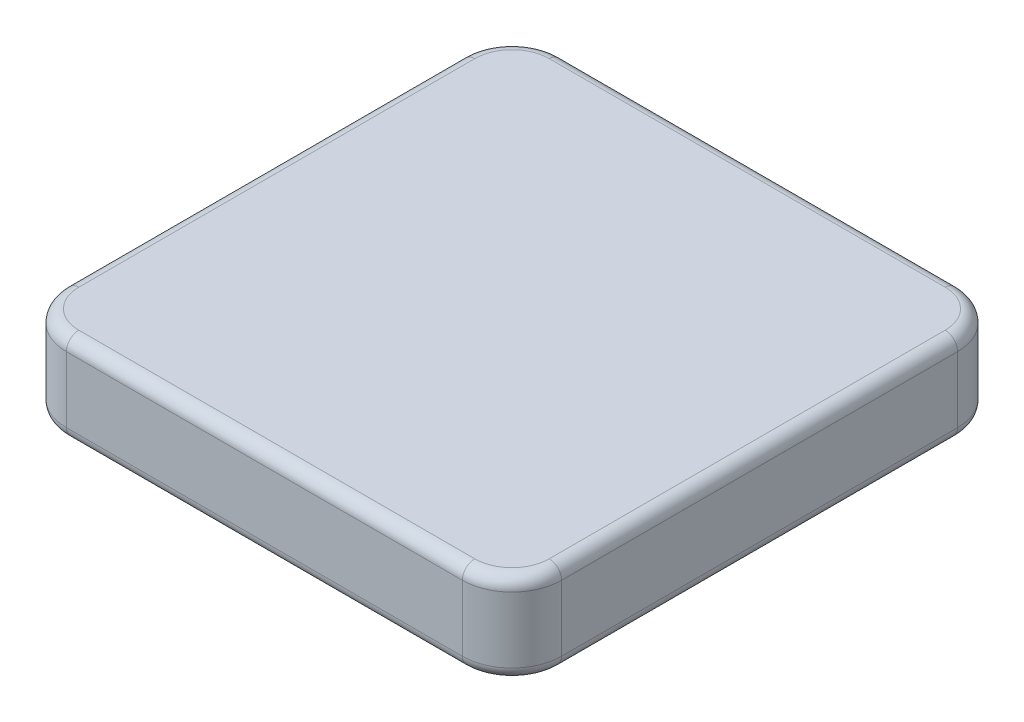
from build123d import *

# Parameters (mm, degrees)
BOSS_EXTRUDE1_DEPTH = 7.3
FILLET1_R           = 1


with BuildPart() as part:
    # Sketch1 → Boss-Extrude1 (new body)
    with BuildSketch(Plane(origin=(0, 0, 0), x_dir=(1, 0, 0), z_dir=(0, 1, 0))):
        with BuildLine():
            Line((4, 0), (35.9, 0))
            ThreePointArc((35.9, 0), (38.728427125, 1.171572875), (39.9, 4))
            Line((39.9, 4), (39.9, 35.9))
            ThreePointArc((39.9, 35.9), (38.728427125, 38.728427125), (35.9, 39.9))
            Line((35.9, 39.9), (4, 39.9))
            ThreePointArc((4, 39.9), (1.171572875, 38.728427125), (0, 35.9))
            Line((0, 35.9), (0, 4))
            ThreePointArc((0, 4), (1.171572875, 1.171572875), (4, 0))
        make_face()
    extrude(amount=BOSS_EXTRUDE1_DEPTH)

    # Fillet1
    fillet1_edges = [part.edges().sort_by_distance(p)[0] for p in [
        (39.9, 0, -19.95),
        (38.728427125, 0, -1.171572875),
        (19.95, 0, 0),
        (1.171572875, 0, -1.171572875),
        (38.728427125, 7.3, -1.171572875),
        (39.9, 7.3, -19.95),
        (38.728427125, 7.3, -38.728427125),
        (19.95, 7.3, -39.9),
        (1.171572875, 7.3, -38.728427125),
        (0, 7.3, -19.95),
        (1.171572875, 7.3, -1.171572875),
        (0, 0, -19.95),
        (19.95, 7.3, 0),
        (1.171572875, 0, -38.728427125),
        (19.95, 0, -39.9),
        (38.728427125, 0, -38.728427125),
    ]]
    fillet(fillet1_edges, radius=FILLET1_R)


solid = part.part
